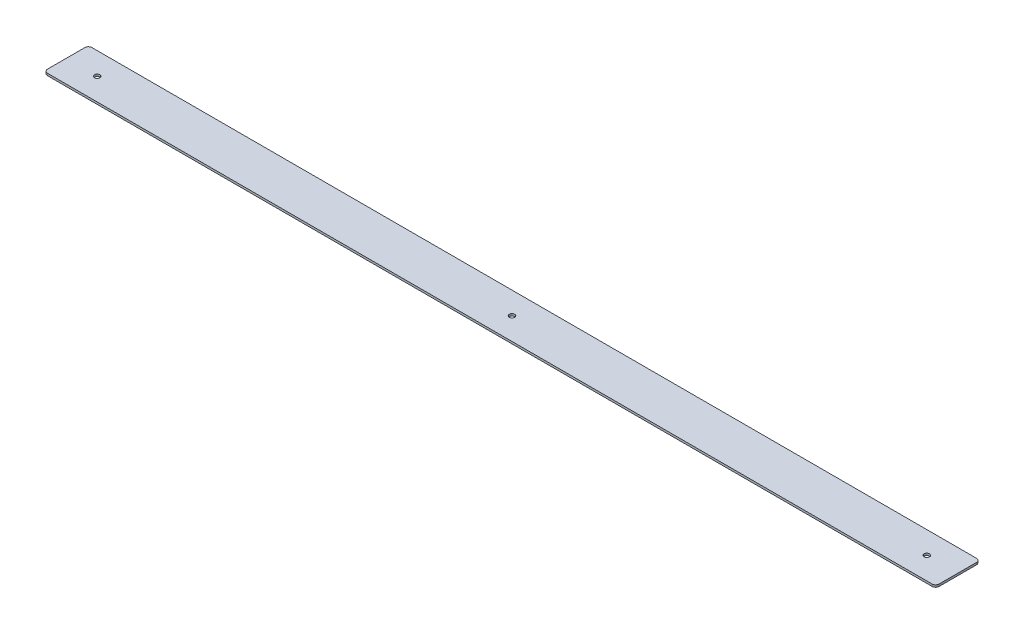
from build123d import *

# Parameters (mm, degrees)
SKETCH1_W           = 636.566333418
SKETCH1_H           = 31.75
BOSS_EXTRUDE1_DEPTH = 1.524
SKETCH2_R           = 1.905
CUT_EXTRUDE1_DEPTH  = 2.524
FILLET1_R           = 2.54


with BuildPart() as part:
    # Sketch1 → Boss-Extrude1 (new body)
    with BuildSketch(Plane(origin=(0, 0, 0), x_dir=(1, 0, 0), z_dir=(0, 1, 0))):
        Rectangle(SKETCH1_W, SKETCH1_H)
    extrude(amount=BOSS_EXTRUDE1_DEPTH)

    # Sketch2 → Cut-Extrude1 (cut, through all)
    with BuildSketch(Plane(origin=(0, 1.524, 0), x_dir=(1, 0, 0), z_dir=(0, 1, 0))):
        with Locations((-296.164, 0)):
            Circle(SKETCH2_R)
        with Locations((296.164, 0)):
            Circle(SKETCH2_R)
        Circle(SKETCH2_R)
    extrude(amount=-CUT_EXTRUDE1_DEPTH, mode=Mode.SUBTRACT)

    # Fillet1
    fillet1_edges = [part.edges().sort_by_distance(p)[0] for p in [
        (318.283166709, 0.762, 15.875),
        (-318.283166709, 0.762, 15.875),
        (-318.283166709, 0.762, -15.875),
        (318.283166709, 0.762, -15.875),
    ]]
    fillet(fillet1_edges, radius=FILLET1_R)


solid = part.part
